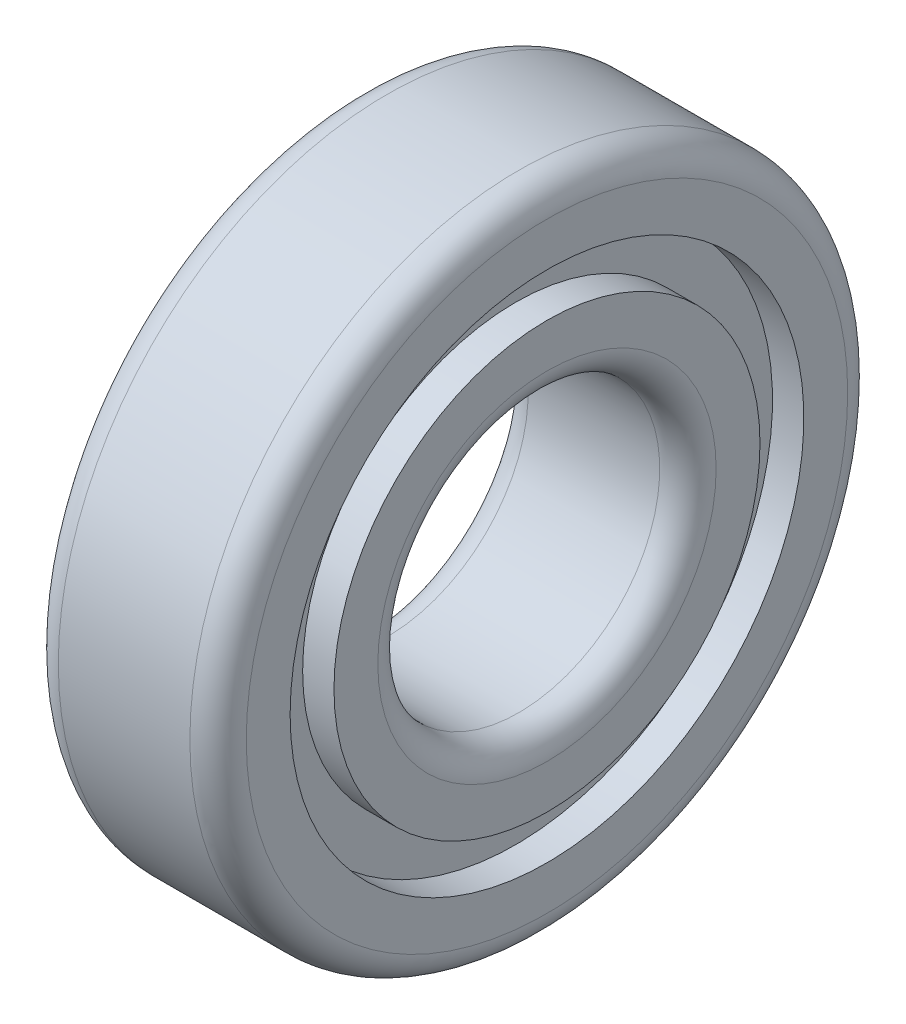
from build123d import *


with BuildPart() as part:
    # Эскиз1 → Повернуть1 (revolve)
    with BuildSketch(Plane.XY):
        with BuildLine():
            Line((0.7, 1.5), (-0.7, 1.5))
            ThreePointArc((-0.7, 1.5), (-0.912132034, 1.587867966), (-1, 1.8))
            Line((-1, 1.8), (-1, 2.266666667))
            Line((-1, 2.266666667), (-0.666666667, 2.266666667))
            Line((-0.666666667, 2.266666667), (-0.666666667, 2.733333333))
            Line((-0.666666667, 2.733333333), (-1, 2.733333333))
            Line((-1, 2.733333333), (-1, 3.2))
            ThreePointArc((-1, 3.2), (-0.912132034, 3.412132034), (-0.7, 3.5))
            Line((-0.7, 3.5), (0.7, 3.5))
            ThreePointArc((0.7, 3.5), (0.912132034, 3.412132034), (1, 3.2))
            Line((1, 3.2), (1, 2.733333333))
            Line((1, 2.733333333), (0.666666667, 2.733333333))
            Line((0.666666667, 2.733333333), (0.666666667, 2.266666667))
            Line((0.666666667, 2.266666667), (1, 2.266666667))
            Line((1, 2.266666667), (1, 1.8))
            ThreePointArc((1, 1.8), (0.912132034, 1.587867966), (0.7, 1.5))
        make_face()
    revolve(axis=Axis((-1000, 0, 0), (1, 0, 0)))


solid = part.part
